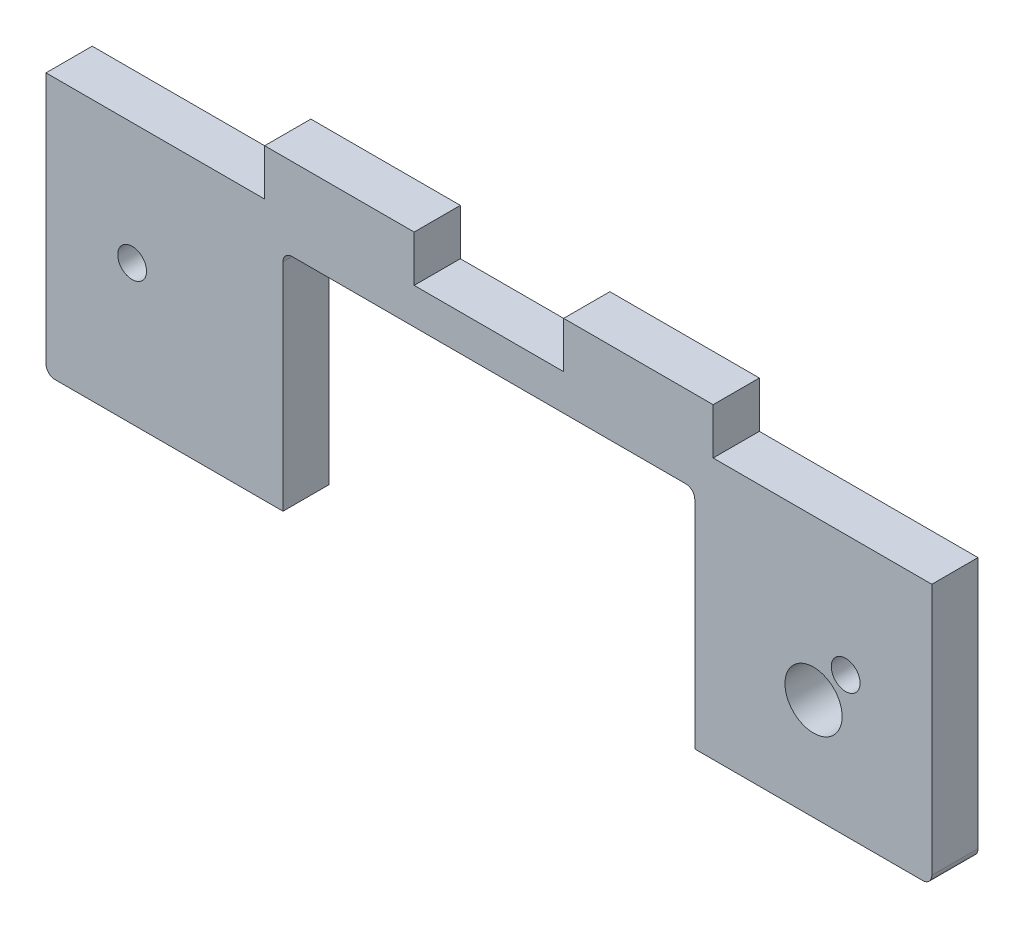
from build123d import *

# Parameters (mm, degrees)
MAIN_DEPTH                  = 5.13
SKETCH2_W                   = 16.6
SKETCH2_H                   = 5.13
TEETH_DEPTH                 = 5.13
M3_CLEARANCE_HOLE1_D        = 3.2
M3_CLEARANCE_HOLE1_DEPTH    = 5.13
HINGE_SLOT_REACH            = 7.13
THERMISTOR_WIRES_HOLE_REACH = 7.13
SKETCH6_R                   = 3.175


with BuildPart() as part:
    # Sketch1 → Main (new body)
    with BuildSketch(Plane.XY):
        with BuildLine():
            Line((-56.488759744, 30.356747088), (41.871240256, 30.356747088))
            Line((41.871240256, 30.356747088), (41.871240256, 2.356747088))
            ThreePointArc((41.871240256, 2.356747088), (41.578347037, 1.649640307), (40.871240256, 1.356747088))
            Line((40.871240256, 1.356747088), (-55.488759744, 1.356747088))
            ThreePointArc((-55.488759744, 1.356747088), (-56.195866525, 1.649640307), (-56.488759744, 2.356747088))
            Line((-56.488759744, 2.356747088), (-56.488759744, 30.356747088))
        make_face()
    extrude(amount=MAIN_DEPTH)

    # Sketch2 → Teeth (add)
    with BuildSketch(Plane(origin=(0, 30.356747088, 0), x_dir=(1, 0, 0), z_dir=(0, 1, 0))):
        with Locations((9.291240256, -2.565)):
            Rectangle(SKETCH2_W, SKETCH2_H)
        with Locations((-23.908759744, -2.565)):
            Rectangle(SKETCH2_W, SKETCH2_H)
    extrude(amount=TEETH_DEPTH)

    # M3 Clearance Hole1
    with Locations(Plane.XY.offset(5.13)):
        with Locations((-46.923759744, 16.856747088), (32.306240256, 16.856747088)):
            Hole(M3_CLEARANCE_HOLE1_D / 2, depth=M3_CLEARANCE_HOLE1_DEPTH)

    # Sketch5 → Hinge slot (cut, up to next)
    with BuildSketch(Plane.XY.offset(5.13), mode=Mode.PRIVATE) as hinge_slot_sk1:
        with BuildLine():
            Line((-29.168759744, 26.356747088), (14.551240256, 26.356747088))
            ThreePointArc((14.551240256, 26.356747088), (15.258347037, 26.06385387), (15.551240256, 25.356747088))
            Line((15.551240256, 25.356747088), (15.551240256, 1.356747088))
            Line((15.551240256, 1.356747088), (-30.168759744, 1.356747088))
            Line((-30.168759744, 1.356747088), (-30.168759744, 25.356747088))
            ThreePointArc((-30.168759744, 25.356747088), (-29.875866525, 26.06385387), (-29.168759744, 26.356747088))
        make_face()
    hinge_slot_tool1 = extrude(hinge_slot_sk1.sketch, amount=-HINGE_SLOT_REACH, mode=Mode.PRIVATE) & part.part
    add(hinge_slot_tool1.solids().sort_by_distance((-7.30876, 13.852135, 5.13))[0], mode=Mode.SUBTRACT)

    # Sketch6 → Thermistor wires hole (cut, up to next)
    with BuildSketch(Plane.XY.offset(5.13), mode=Mode.PRIVATE) as thermistor_wires_hole_sk1:
        with Locations((28.738240256, 12.652139603)):
            Circle(SKETCH6_R)
    thermistor_wires_hole_tool1 = extrude(thermistor_wires_hole_sk1.sketch, amount=-THERMISTOR_WIRES_HOLE_REACH, mode=Mode.PRIVATE) & part.part
    add(thermistor_wires_hole_tool1.solids().sort_by_distance((28.73824, 12.65214, 5.13))[0], mode=Mode.SUBTRACT)


solid = part.part
